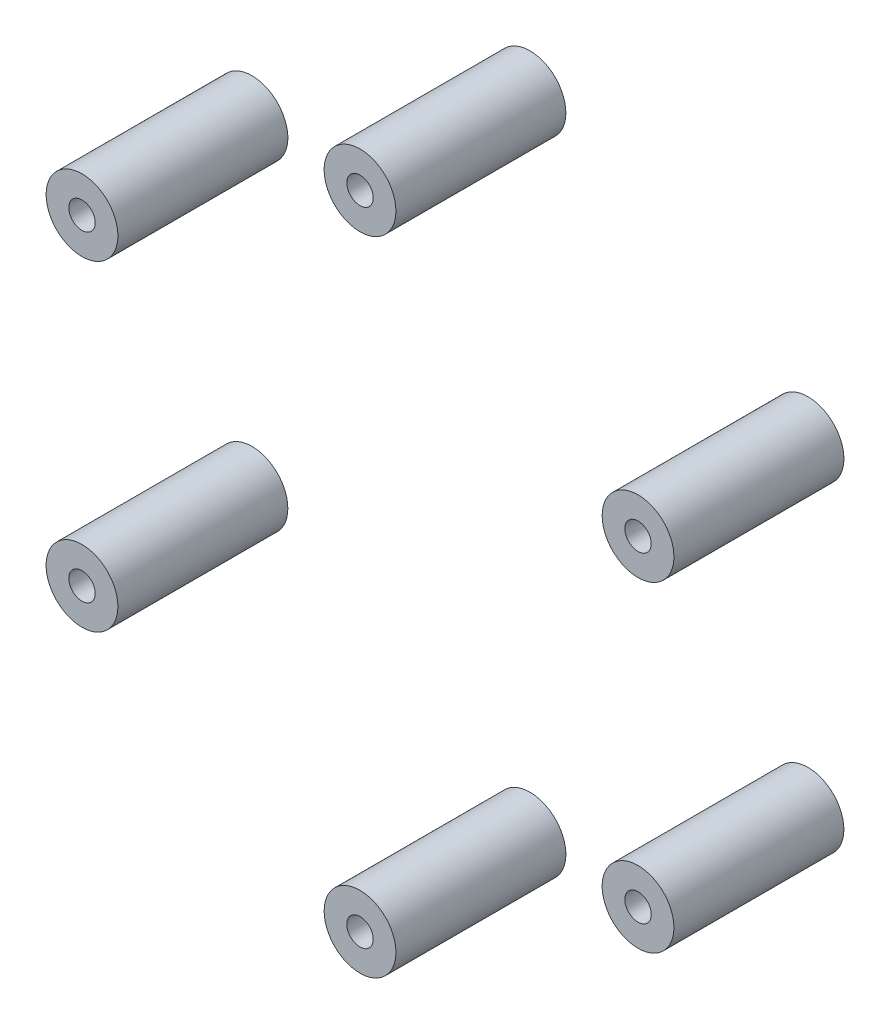
from build123d import *

# Parameters (mm, degrees)
SCREW_HOLE_R        = 3.8
SCREW_HOLE_R_2      = 1.4
BOSS_EXTRUDE1_DEPTH = 9
CIRPATTERN1_COUNT   = 6


with BuildPart() as part:
    # Screw Hole → Boss-Extrude1 (new, symmetric)
    with BuildSketch(Plane.XY):
        with Locations((0, 34)):
            Circle(SCREW_HOLE_R)
        with Locations((0, 34)):
            Circle(SCREW_HOLE_R_2, mode=Mode.SUBTRACT)
    extrude(amount=BOSS_EXTRUDE1_DEPTH, both=True)


with BuildPart() as cirpattern1_1:
    # CirPattern1: pattern copy
    add(part.part.rotate(Axis((0, 0, 0), (0, 0, 1)), 1 * 360 / CIRPATTERN1_COUNT))


with BuildPart() as cirpattern1_2:
    # CirPattern1: pattern copy
    add(part.part.rotate(Axis((0, 0, 0), (0, 0, 1)), 2 * 360 / CIRPATTERN1_COUNT))


with BuildPart() as cirpattern1_3:
    # CirPattern1: pattern copy
    add(part.part.rotate(Axis((0, 0, 0), (0, 0, 1)), 3 * 360 / CIRPATTERN1_COUNT))


with BuildPart() as cirpattern1_4:
    # CirPattern1: pattern copy
    add(part.part.rotate(Axis((0, 0, 0), (0, 0, 1)), 4 * 360 / CIRPATTERN1_COUNT))


with BuildPart() as cirpattern1_5:
    # CirPattern1: pattern copy
    add(part.part.rotate(Axis((0, 0, 0), (0, 0, 1)), 5 * 360 / CIRPATTERN1_COUNT))


solid = Compound([part.part, cirpattern1_1.part, cirpattern1_2.part, cirpattern1_3.part, cirpattern1_4.part, cirpattern1_5.part])
